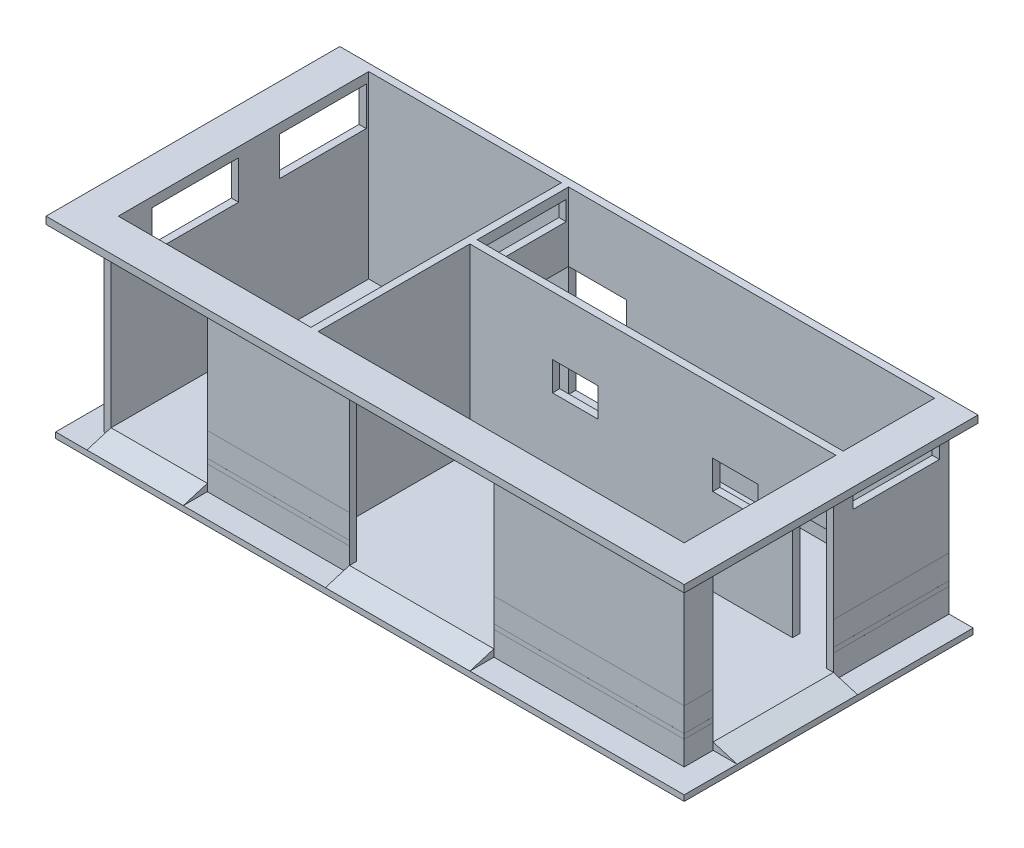
from build123d import *

# Parameters (mm, degrees)
CROQUIS1_W               = 7900
CROQUIS1_H               = 3730
SALIENTE_EXTRUIR1_DEPTH  = 5500
CROQUIS2_W               = 7600
CROQUIS2_H               = 5200
CORTAR_EXTRUIR1_DEPTH    = 3250
CROQUIS3_W               = 7600
CROQUIS3_H               = 150
SALIENTE_EXTRUIR2_DEPTH  = 3250
CROQUIS4_W               = 800
CROQUIS4_H               = 2300
CORTAR_EXTRUIR2_DEPTH    = 150
CROQUIS7_W               = 5500
CROQUIS7_H               = 3730
SALIENTE_EXTRUIR4_DEPTH  = 4150
CROQUIS8_W               = 4000
CROQUIS8_H               = 5200
CORTAR_EXTRUIR3_DEPTH    = 3250
CROQUIS10_W              = 900
CROQUIS10_H              = 150
CORTAR_EXTRUIR5_DEPTH    = 2300
CROQUIS11_W              = 2500
CROQUIS11_H              = 3400
CORTAR_EXTRUIR6_DEPTH    = 150
CROQUIS12_W              = 1800
CROQUIS12_H              = 800
CORTAR_EXTRUIR7_DEPTH    = 150
CROQUIS13_W              = 3000
CROQUIS13_H              = 3400
CORTAR_EXTRUIR8_DEPTH    = 150
CROQUIS15_W              = 1800
CROQUIS15_H              = 800
CORTAR_EXTRUIR10_DEPTH   = 150
CROQUIS16_W              = 2000
CROQUIS16_H              = 2300
CORTAR_EXTRUIR11_DEPTH   = 150
CROQUIS17_W              = 12050
CROQUIS17_H              = 150
SALIENTE_EXTRUIR5_DEPTH  = 600
CROQUIS18_W              = 6100
CROQUIS18_H              = 150
SALIENTE_EXTRUIR6_DEPTH  = 600
CROQUIS19_W              = 6100
CROQUIS19_H              = 150
SALIENTE_EXTRUIR7_DEPTH  = 600
CROQUIS20_W              = 7600
CROQUIS20_H              = 1900
CROQUIS20_H_2            = 3150
CROQUIS20_W_2            = 4000
CROQUIS20_H_3            = 5200
CORTAR_EXTRUIR12_DEPTH   = 1280
CROQUIS21_W              = 2000
CROQUIS21_H              = 3400
CORTAR_EXTRUIR13_DEPTH   = 150
CROQUIS24_W              = 2000
CROQUIS24_H              = 2300
SALIENTE_EXTRUIR11_DEPTH = 150
CROQUIS25_W              = 1800
CROQUIS25_H              = 400
CORTAR_EXTRUIR14_DEPTH   = 170
CROQUIS26_W              = 12050
CROQUIS26_H              = 5500
SALIENTE_EXTRUIR12_DEPTH = 270
SALIENTE_EXTRUIR13_DEPTH = 120
CROQUIS33_W              = 2500
CROQUIS33_H              = 150
SALIENTE_EXTRUIR19_DEPTH = 500
CROQUIS34_W              = 2000
CROQUIS34_H              = 150
CROQUIS34_W_2            = 3000
SALIENTE_EXTRUIR20_DEPTH = 500
CORTAR_EXTRUIR15_DEPTH   = 7950
CORTAR_EXTRUIR16_DEPTH   = 2500
CROQUIS37_W              = 5500
CROQUIS37_H              = 500
CORTAR_EXTRUIR17_DEPTH   = 0.1
CROQUIS38_W              = 2950
CROQUIS38_H              = 500
CROQUIS38_W_2            = 3950
CORTAR_EXTRUIR18_DEPTH   = 0.1
CROQUIS40_W              = 2400
CROQUIS40_H              = 500
CORTAR_EXTRUIR21_DEPTH   = 0.1
CROQUIS42_W              = 5500
CROQUIS42_H              = 858.801282929
CORTAR_EXTRUIR24_DEPTH   = 0.1
CROQUIS43_W              = 2950
CROQUIS43_H              = 500
CROQUIS43_W_2            = 3950
CORTAR_EXTRUIR25_DEPTH   = 0.1
CROQUIS44_W              = 599.9
CROQUIS44_H              = 500
CROQUIS44_W_2            = 2400
CROQUIS44_H_2            = 499.99998
CORTAR_EXTRUIR26_DEPTH   = 0.1
CROQUIS47_W              = 1200
CROQUIS47_H              = 2300
CORTAR_EXTRUIR28_DEPTH   = 150
CROQUIS48_W              = 1800
CROQUIS48_H              = 800
CORTAR_EXTRUIR29_DEPTH   = 150
CROQUIS50_W              = 944
CROQUIS50_H              = 600
CORTAR_EXTRUIR30_DEPTH   = 150


with BuildPart() as part:
    # Croquis1 → Saliente-Extruir1 (new body)
    with BuildSketch(Plane.XY):
        Rectangle(CROQUIS1_W, CROQUIS1_H)
    extrude(amount=SALIENTE_EXTRUIR1_DEPTH)

    # Croquis2 → Cortar-Extruir1 (cut)
    with BuildSketch(Plane.XZ.offset(1865)):
        with Locations((0, 2750)):
            Rectangle(CROQUIS2_W, CROQUIS2_H)
    extrude(amount=-CORTAR_EXTRUIR1_DEPTH, mode=Mode.SUBTRACT)

    # Croquis3 → Saliente-Extruir2 (add)
    with BuildSketch(Plane.XZ.offset(1865)):
        with Locations((0, 2125)):
            Rectangle(CROQUIS3_W, CROQUIS3_H)
    extrude(amount=-SALIENTE_EXTRUIR2_DEPTH)

    # Croquis4 → Cortar-Extruir2 (cut)
    with BuildSketch(Plane.ZY.offset(3950)):
        with Locations((550, -715)):
            Rectangle(CROQUIS4_W, CROQUIS4_H)
    extrude(amount=-CORTAR_EXTRUIR2_DEPTH, mode=Mode.SUBTRACT)

    # Croquis7 → Saliente-Extruir4 (add)
    with BuildSketch(Plane.ZY.offset(3950)):
        with Locations((2750, 0)):
            Rectangle(CROQUIS7_W, CROQUIS7_H)
    extrude(amount=SALIENTE_EXTRUIR4_DEPTH)

    # Croquis8 → Cortar-Extruir3 (cut)
    with BuildSketch(Plane.XZ.offset(1865)):
        with Locations((-5950, 2750)):
            Rectangle(CROQUIS8_W, CROQUIS8_H)
    extrude(amount=-CORTAR_EXTRUIR3_DEPTH, mode=Mode.SUBTRACT)

    # Croquis10 → Cortar-Extruir5 (cut)
    with BuildSketch(Plane.XZ.offset(1865)):
        with Locations((3350, 2125)):
            Rectangle(CROQUIS10_W, CROQUIS10_H)
    extrude(amount=-CORTAR_EXTRUIR5_DEPTH, mode=Mode.SUBTRACT)

    # Croquis11 → Cortar-Extruir6 (cut)
    with BuildSketch(Plane(origin=(3950, 0, 0), x_dir=(0, 0, -1), z_dir=(1, 0, 0))):
        with Locations((-3650, -165)):
            Rectangle(CROQUIS11_W, CROQUIS11_H)
    extrude(amount=-CORTAR_EXTRUIR6_DEPTH, mode=Mode.SUBTRACT)

    # Croquis12 → Cortar-Extruir7 (cut)
    with BuildSketch(Plane(origin=(3950, 0, 0), x_dir=(0, 0, -1), z_dir=(1, 0, 0))):
        with Locations((-1100, 1265)):
            Rectangle(CROQUIS12_W, CROQUIS12_H)
    extrude(amount=-CORTAR_EXTRUIR7_DEPTH, mode=Mode.SUBTRACT)

    # Croquis13 → Cortar-Extruir8 (cut)
    with BuildSketch(Plane.XY.offset(5500)):
        with Locations((-1500, -165)):
            Rectangle(CROQUIS13_W, CROQUIS13_H)
    extrude(amount=-CORTAR_EXTRUIR8_DEPTH, mode=Mode.SUBTRACT)

    # Croquis15 → Cortar-Extruir10 (cut)
    with BuildSketch(Plane.ZY.offset(8100)):
        with Locations((1100, 1265)):
            Rectangle(CROQUIS15_W, CROQUIS15_H)
    extrude(amount=-CORTAR_EXTRUIR10_DEPTH, mode=Mode.SUBTRACT)

    # Croquis16 → Cortar-Extruir11 (cut)
    with BuildSketch(Plane(origin=(0, 0, 0), x_dir=(-1, 0, 0), z_dir=(0, 0, -1))):
        with Locations((5950, -715)):
            Rectangle(CROQUIS16_W, CROQUIS16_H)
    extrude(amount=-CORTAR_EXTRUIR11_DEPTH, mode=Mode.SUBTRACT)

    # Croquis17 → Saliente-Extruir5 (add)
    with BuildSketch(Plane.XY.offset(5500)):
        with Locations((-2075, 1790)):
            Rectangle(CROQUIS17_W, CROQUIS17_H)
    extrude(amount=SALIENTE_EXTRUIR5_DEPTH)

    # Croquis18 → Saliente-Extruir6 (add)
    with BuildSketch(Plane(origin=(3950, 0, 0), x_dir=(0, 0, -1), z_dir=(1, 0, 0))):
        with Locations((-3050, 1790)):
            Rectangle(CROQUIS18_W, CROQUIS18_H)
    extrude(amount=SALIENTE_EXTRUIR6_DEPTH)

    # Croquis19 → Saliente-Extruir7 (add)
    with BuildSketch(Plane.ZY.offset(8100)):
        with Locations((3050, 1790)):
            Rectangle(CROQUIS19_W, CROQUIS19_H)
    extrude(amount=SALIENTE_EXTRUIR7_DEPTH)

    # Croquis20 → Cortar-Extruir12 (cut)
    with BuildSketch(Plane.XZ.offset(-1385)):
        with Locations((0, 1100)):
            Rectangle(CROQUIS20_W, CROQUIS20_H)
        with Locations((0, 3775)):
            Rectangle(CROQUIS20_W, CROQUIS20_H_2)
        with Locations((-5950, 2750)):
            Rectangle(CROQUIS20_W_2, CROQUIS20_H_3)
    extrude(amount=-CORTAR_EXTRUIR12_DEPTH, mode=Mode.SUBTRACT)

    # Croquis21 → Cortar-Extruir13 (cut)
    with BuildSketch(Plane.XY.offset(5500)):
        with Locations((-6950, -165)):
            Rectangle(CROQUIS21_W, CROQUIS21_H)
    extrude(amount=-CORTAR_EXTRUIR13_DEPTH, mode=Mode.SUBTRACT)

    # Croquis24 → Saliente-Extruir11 (add)
    with BuildSketch(Plane(origin=(0, 0, 0), x_dir=(-1, 0, 0), z_dir=(0, 0, -1))):
        with Locations((5950, -715)):
            Rectangle(CROQUIS24_W, CROQUIS24_H)
    extrude(amount=-SALIENTE_EXTRUIR11_DEPTH)

    # Croquis25 → Cortar-Extruir14 (cut)
    with BuildSketch(Plane(origin=(-3800, 0, 0), x_dir=(0, 0, -1), z_dir=(1, 0, 0))):
        with Locations((-1100, 1465)):
            Rectangle(CROQUIS25_W, CROQUIS25_H)
    extrude(amount=-CORTAR_EXTRUIR14_DEPTH, mode=Mode.SUBTRACT)

    # Croquis26 → Saliente-Extruir12 (add)
    with BuildSketch(Plane.XZ.offset(1865)):
        with Locations((-2075, 2750)):
            Rectangle(CROQUIS26_W, CROQUIS26_H)
    extrude(amount=SALIENTE_EXTRUIR12_DEPTH)



with BuildPart() as body_2:
    # Croquis27 → Saliente-Extruir13 (new body)
    with BuildSketch(Plane.XZ.offset(2135)):
        Polygon((-8100, 0), (-8100, 5500), (3950, 5500), (3950, 0), (4450, 0), (4450, 6000), (-8600, 6000), (-8600, 0), align=None)
    extrude(amount=-SALIENTE_EXTRUIR13_DEPTH)


with BuildPart() as part_1:
    add(part.part)

    add(body_2.part)  # Saliente-Extruir19 merges body 2
    # Croquis33 → Saliente-Extruir19 (add)
    with BuildSketch(Plane(origin=(3950, 0, 0), x_dir=(0, 0, -1), z_dir=(1, 0, 0))):
        with Locations((-3650, -1940)):
            Rectangle(CROQUIS33_W, CROQUIS33_H)
    extrude(amount=SALIENTE_EXTRUIR19_DEPTH)

    # Croquis34 → Saliente-Extruir20 (add)
    with BuildSketch(Plane.XY.offset(5500)):
        with Locations((-6950, -1940)):
            Rectangle(CROQUIS34_W, CROQUIS34_H)
        with Locations((-1500, -1940)):
            Rectangle(CROQUIS34_W_2, CROQUIS34_H)
    extrude(amount=SALIENTE_EXTRUIR20_DEPTH)

    # Croquis35 → Cortar-Extruir15 (cut)
    with BuildSketch(Plane.ZY.offset(7950)):
        Polygon((6000, -2015), (5500, -1865), (6000, -1865), align=None)
    extrude(amount=-CORTAR_EXTRUIR15_DEPTH, mode=Mode.SUBTRACT)

    # Croquis36 → Cortar-Extruir16 (cut)
    with BuildSketch(Plane(origin=(0, 0, 2400), x_dir=(-1, 0, 0), z_dir=(0, 0, -1))):
        Polygon((-4450, -1865), (-3950, -1865), (-4450, -2015), align=None)
    extrude(amount=-CORTAR_EXTRUIR16_DEPTH, mode=Mode.SUBTRACT)

    # Croquis37 → Cortar-Extruir17 (cut)
    with BuildSketch(Plane.ZY.offset(8100)):
        with Locations((2750, -1765)):
            Rectangle(CROQUIS37_W, CROQUIS37_H)
    extrude(amount=-CORTAR_EXTRUIR17_DEPTH, mode=Mode.SUBTRACT)

    # Croquis38 → Cortar-Extruir18 (cut)
    with BuildSketch(Plane.XY.offset(5500)):
        with Locations((-4475, -1765)):
            Rectangle(CROQUIS38_W, CROQUIS38_H)
        with Locations((1975, -1765)):
            Rectangle(CROQUIS38_W_2, CROQUIS38_H)
    extrude(amount=-CORTAR_EXTRUIR18_DEPTH, mode=Mode.SUBTRACT)

    # Croquis40 → Cortar-Extruir21 (cut)
    with BuildSketch(Plane(origin=(3950, 0, 0), x_dir=(0, 0, -1), z_dir=(1, 0, 0))):
        with Locations((-1200, -1765)):
            Rectangle(CROQUIS40_W, CROQUIS40_H)
        Polygon((-4900, -2015), (-4900, -1515.00001), (-5500, -1515.00001), (-5499.9, -2015), align=None)
    extrude(amount=-CORTAR_EXTRUIR21_DEPTH, mode=Mode.SUBTRACT)

    # Croquis42 → Cortar-Extruir24 (cut)
    with BuildSketch(Plane.ZY.offset(8100)):
        with Locations((2750, -985.599358535)):
            Rectangle(CROQUIS42_W, CROQUIS42_H)
    extrude(amount=-CORTAR_EXTRUIR24_DEPTH, mode=Mode.SUBTRACT)

    # Croquis43 → Cortar-Extruir25 (cut)
    with BuildSketch(Plane.XY.offset(5500)):
        with Locations((-4475, -1165)):
            Rectangle(CROQUIS43_W, CROQUIS43_H)
        with Locations((1975, -1165)):
            Rectangle(CROQUIS43_W_2, CROQUIS43_H)
    extrude(amount=-CORTAR_EXTRUIR25_DEPTH, mode=Mode.SUBTRACT)

    # Croquis44 → Cortar-Extruir26 (cut)
    with BuildSketch(Plane(origin=(3950, 0, 0), x_dir=(0, 0, -1), z_dir=(1, 0, 0))):
        with Locations((-5199.95, -1165.00001)):
            Rectangle(CROQUIS44_W, CROQUIS44_H)
        with Locations((-1200, -1165.00001)):
            Rectangle(CROQUIS44_W_2, CROQUIS44_H_2)
    extrude(amount=-CORTAR_EXTRUIR26_DEPTH, mode=Mode.SUBTRACT)

    # Croquis47 → Cortar-Extruir28 (cut)
    with BuildSketch(Plane(origin=(0, 0, 0), x_dir=(-1, 0, 0), z_dir=(0, 0, -1))):
        with Locations((3200, -715)):
            Rectangle(CROQUIS47_W, CROQUIS47_H)
    extrude(amount=-CORTAR_EXTRUIR28_DEPTH, mode=Mode.SUBTRACT)

    # Croquis48 → Cortar-Extruir29 (cut)
    with BuildSketch(Plane.ZY.offset(8100)):
        with Locations((3750, 1265)):
            Rectangle(CROQUIS48_W, CROQUIS48_H)
    extrude(amount=-CORTAR_EXTRUIR29_DEPTH, mode=Mode.SUBTRACT)

    # Croquis50 → Cortar-Extruir30 (cut)
    with BuildSketch(Plane.XY.offset(2200)):
        with Locations((-1612, 345)):
            Rectangle(CROQUIS50_W, CROQUIS50_H)
        with Locations((1714, 235)):
            Rectangle(CROQUIS50_W, CROQUIS50_H)
    extrude(amount=-CORTAR_EXTRUIR30_DEPTH, mode=Mode.SUBTRACT)


solid = part_1.part
